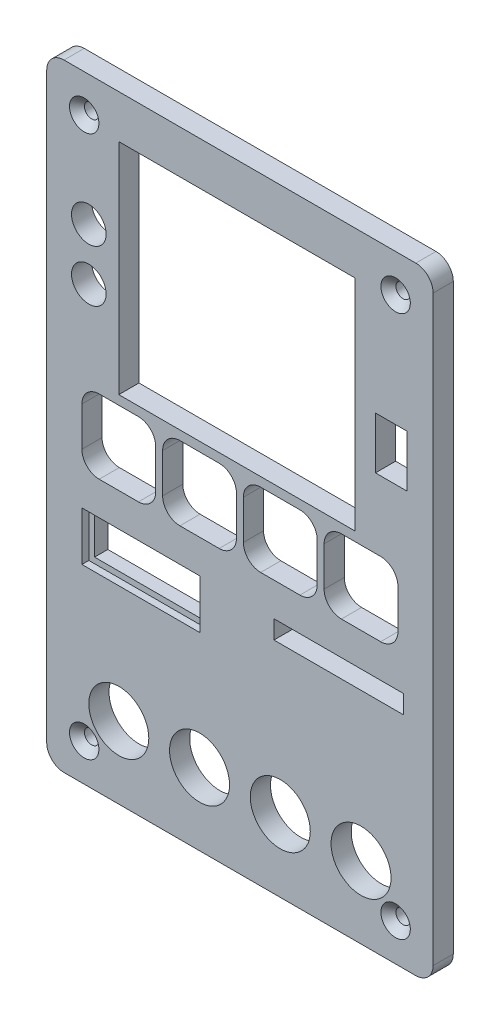
from build123d import *

# Parameters (mm, degrees)
SKICA1_W                 = 67
SKICA1_H                 = 107
P_IDAT_VYSUNUT_M1_DEPTH  = 3.5
ZAOBLIT1_R               = 3
SKICA2_R                 = 1.25
SKICA2_R_2               = 3
SKICA2_R_3               = 5.2
SKICA2_W                 = 41
SKICA2_H                 = 38
SKICA2_W_2               = 5.5
SKICA2_H_2               = 9
SKICA2_W_3               = 12.8
SKICA2_H_3               = 12.8
SKICA2_W_4               = 22.5
SKICA2_H_4               = 3.2
ODEBRAT_VYSUNUT_M1_DEPTH = 4.5
ZAOBLIT2_R               = 3
SKICA3_W                 = 22
SKICA3_H                 = 3
ODEBRAT_VYSUNUT_M2_DEPTH = 2
ZKOSEN_1_SIZE            = 1.3
SKICA4_W                 = 20.5
SKICA4_H                 = 8.5
ODEBRAT_VYSUNUT_M3_DEPTH = 1.2
SKICA5_W                 = 18.5
SKICA5_H                 = 6.5
ODEBRAT_VYSUNUT_M4_DEPTH = 3.3


with BuildPart() as part:
    # Skica1 → Přidat vysunutím1 (new body)
    with BuildSketch(Plane.XY):
        with Locations((33.5, 53.5)):
            Rectangle(SKICA1_W, SKICA1_H)
    extrude(amount=P_IDAT_VYSUNUT_M1_DEPTH)

    # Zaoblit1
    zaoblit1_edges = [part.edges().sort_by_distance(p)[0] for p in [
        (0, 107, 1.75),
        (67, 107, 1.75),
        (67, 0, 1.75),
        (0, 0, 1.75),
    ]]
    fillet(zaoblit1_edges, radius=ZAOBLIT1_R)

    # Skica2 → Odebrat vysunutím1 (cut, through all)
    with BuildSketch(Plane.XY.offset(3.5)):
        with Locations((6.5, 100.5)):
            Circle(SKICA2_R)
        with Locations((60.5, 100.5)):
            Circle(SKICA2_R)
        with Locations((6.5, 6.5)):
            Circle(SKICA2_R)
        with Locations((60.5, 6.5)):
            Circle(SKICA2_R)
        with Locations((7.3, 75.5)):
            Circle(SKICA2_R_2)
        with Locations((12.5, 12.5)):
            Circle(SKICA2_R_3)
        with Locations((26.5, 12.5)):
            Circle(SKICA2_R_3)
        with Locations((40.5, 12.5)):
            Circle(SKICA2_R_3)
        with Locations((54.5, 12.5)):
            Circle(SKICA2_R_3)
        with Locations((7.3, 84.5)):
            Circle(SKICA2_R_2)
        with Locations((33, 80.5)):
            Rectangle(SKICA2_W, SKICA2_H)
        with Locations((59.75, 76.5)):
            Rectangle(SKICA2_W_2, SKICA2_H_2)
        with Locations((54.5, 53.5)):
            Rectangle(SKICA2_W_3, SKICA2_H_3)
        with Locations((40.5, 53.5)):
            Rectangle(SKICA2_W_3, SKICA2_H_3)
        with Locations((26.5, 53.5)):
            Rectangle(SKICA2_W_3, SKICA2_H_3)
        with Locations((12.5, 53.5)):
            Rectangle(SKICA2_W_3, SKICA2_H_3)
        with Locations((50.65, 39.7)):
            Rectangle(SKICA2_W_4, SKICA2_H_4)
    extrude(amount=-ODEBRAT_VYSUNUT_M1_DEPTH, mode=Mode.SUBTRACT)

    # Zaoblit2
    zaoblit2_edges = [part.edges().sort_by_distance(p)[0] for p in [
        (6.1, 47.1, 1.75),
        (6.1, 59.9, 1.75),
        (18.9, 59.9, 1.75),
        (18.9, 47.1, 1.75),
        (20.1, 47.1, 1.75),
        (20.1, 59.9, 1.75),
        (32.9, 59.9, 1.75),
        (32.9, 47.1, 1.75),
        (34.1, 47.1, 1.75),
        (34.1, 59.9, 1.75),
        (46.9, 59.9, 1.75),
        (46.9, 47.1, 1.75),
        (48.1, 47.1, 1.75),
        (48.1, 59.9, 1.75),
        (60.9, 59.9, 1.75),
        (60.9, 47.1, 1.75),
    ]]
    fillet(zaoblit2_edges, radius=ZAOBLIT2_R)

    # Skica3 → Odebrat vysunutím2 (cut)
    with BuildSketch(Plane(origin=(0, 0, 0), x_dir=(-1, 0, 0), z_dir=(0, 0, -1))):
        with Locations((-33, 101)):
            Rectangle(SKICA3_W, SKICA3_H)
    extrude(amount=-ODEBRAT_VYSUNUT_M2_DEPTH, mode=Mode.SUBTRACT)

    # Zkosení1
    zkosen_1_edges = [part.edges().sort_by_distance(p)[0] for p in [
        (5.25, 6.5, 3.5),
        (59.25, 6.5, 3.5),
        (5.25, 100.5, 3.5),
        (59.25, 100.5, 3.5),
    ]]
    chamfer(zkosen_1_edges, length=ZKOSEN_1_SIZE)

    # Skica4 → Odebrat vysunutím3 (cut)
    with BuildSketch(Plane.XY.offset(3.5)):
        with Locations((16.35, 37.05)):
            Rectangle(SKICA4_W, SKICA4_H)
    extrude(amount=-ODEBRAT_VYSUNUT_M3_DEPTH, mode=Mode.SUBTRACT)

    # Skica5 → Odebrat vysunutím4 (cut, through all)
    with BuildSketch(Plane.XY.offset(2.3)):
        with Locations((16.35, 37.05)):
            Rectangle(SKICA5_W, SKICA5_H)
    extrude(amount=-ODEBRAT_VYSUNUT_M4_DEPTH, mode=Mode.SUBTRACT)


solid = part.part
